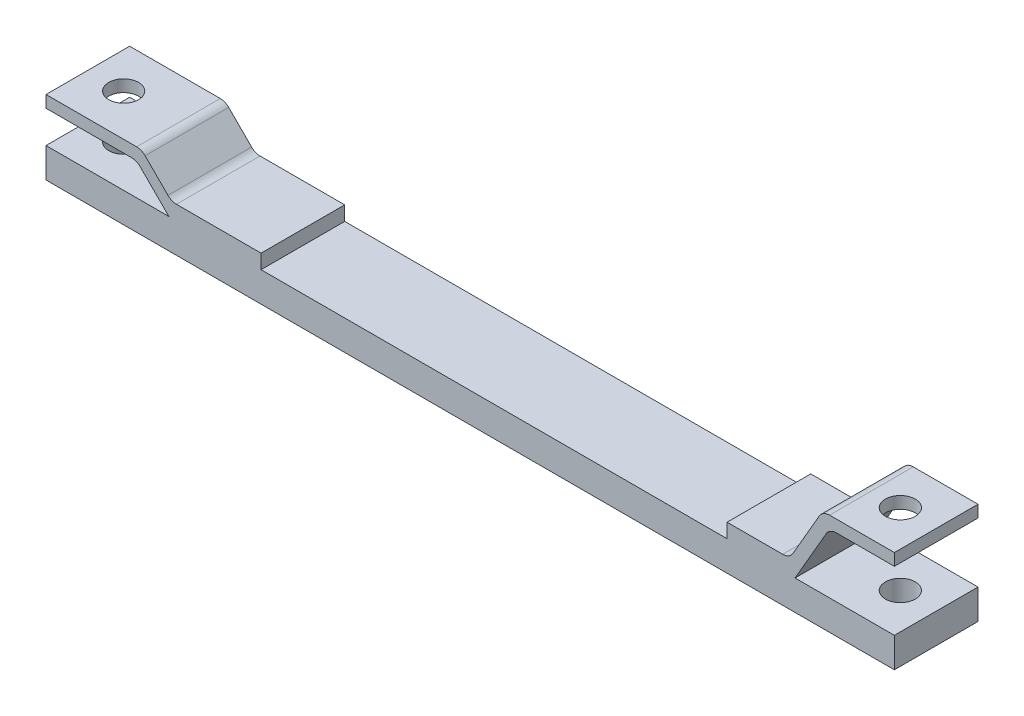
from build123d import *

# Parameters (mm, degrees)
BOSS_EXTRUDE1_DEPTH = 70
FILLET1_R           = 10
FILLET2_R           = 10
SKETCH2_R           = 12.5
CUT_EXTRUDE1_DEPTH  = 86


with BuildPart() as part:
    # Sketch1 → Boss-Extrude1 (new body)
    with BuildSketch(Plane.XY):
        Polygon((0, 62), (0, 52), (75.857864376, 52), (102.857864376, 25), (0, 25), (0, 0), (710, 0), (710, 25), (626.905989232, 25), (655.773502692, 75), (710, 75), (710, 85), (650, 85), (622.287187079, 37), (570, 37), (570, 25), (180, 25), (180, 37), (105, 37), (80, 62), align=None)
    extrude(amount=BOSS_EXTRUDE1_DEPTH)

    # Fillet1
    fillet1_edges = [part.edges().sort_by_distance(p)[0] for p in [
        (80, 62, 35),
        (105, 37, 35),
        (650, 85, 35),
        (622.287187079, 37, 35),
    ]]
    fillet(fillet1_edges, radius=FILLET1_R)

    # Fillet2
    fillet2_edges = [part.edges().sort_by_distance(p)[0] for p in [
        (75.857864376, 52, 35),
        (655.773502692, 75, 35),
    ]]
    fillet(fillet2_edges, radius=FILLET2_R)

    # Sketch2 → Cut-Extrude1 (cut, through all)
    with BuildSketch(Plane(origin=(0, 85, 0), x_dir=(1, 0, 0), z_dir=(0, 1, 0))):
        with Locations((680, -35)):
            Circle(SKETCH2_R)
        with Locations((30, -35)):
            Circle(SKETCH2_R)
    extrude(amount=-CUT_EXTRUDE1_DEPTH, mode=Mode.SUBTRACT)


solid = part.part
